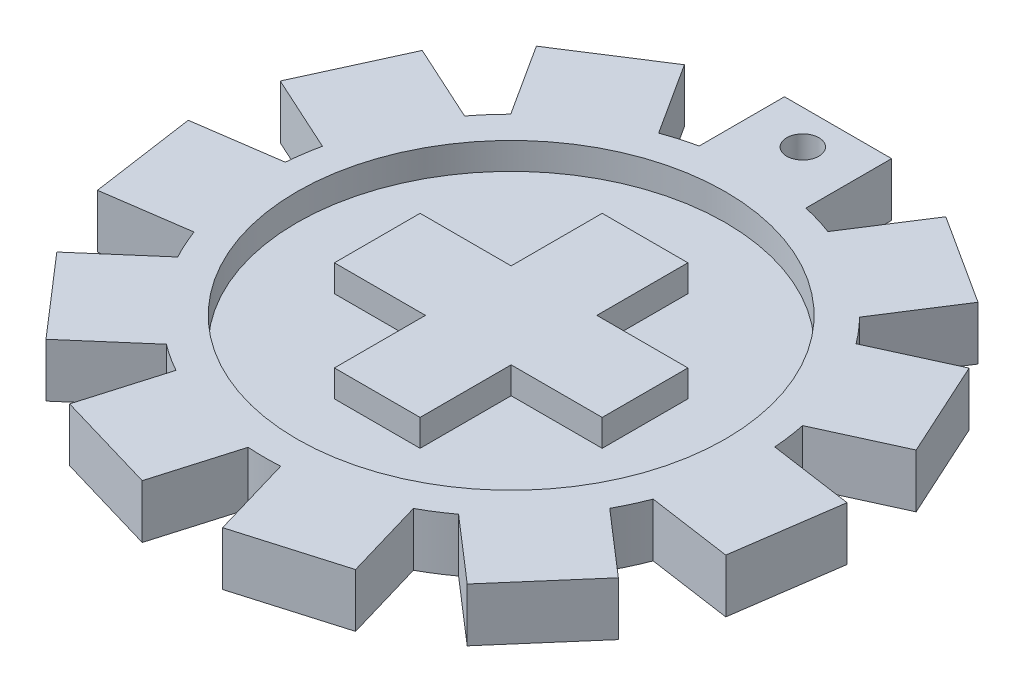
from build123d import *

# Parameters (mm, degrees)
SKETCH1_R           = 20
BOSS_EXTRUDE1_DEPTH = 2.5
SKETCH1_4_R         = 20
BOSS_EXTRUDE2_DEPTH = 5
SKETCH3_R           = 1.5
CUT_EXTRUDE1_DEPTH  = 7


with BuildPart() as part:
    # Sketch1 → Boss-Extrude1 (new body)
    with BuildSketch(Plane(origin=(0, 0, 0), x_dir=(1, 0, 0), z_dir=(0, 1, 0))):
        Circle(SKETCH1_R)
        Polygon((-12.5, -4), (-12.5, 4), (-4, 4), (-4, 12.5), (4, 12.5), (4, 4), (12.5, 4), (12.5, -4), (4, -4), (4, -12.5), (-4, -12.5), (-4, -4), align=None, mode=Mode.SUBTRACT)
    extrude(amount=BOSS_EXTRUDE1_DEPTH)

    # Sketch1_4 → Boss-Extrude2 (add)
    with BuildSketch(Plane(origin=(0, 0, 0), x_dir=(1, 0, 0), z_dir=(0, 1, 0))):
        with BuildLine():
            Line((-4.915686496, 30.430999893), (-4.915686496, 22.468556391))
            ThreePointArc((-4.915686496, 22.468556391), (-6.396922743, 22.09251863), (-7.849917421, 21.618945314))
            Line((-7.849917421, 21.618945314), (-12.175043961, 28.348973577))
            Line((-12.175043961, 28.348973577), (-20.587579289, 22.942565402))
            Line((-20.587579289, 22.942565402), (-16.282757325, 16.244131676))
            ThreePointArc((-16.282757325, 16.244131676), (-17.325551189, 15.126971805), (-18.29185503, 13.94302835))
            Line((-18.29185503, 13.94302835), (-25.568910993, 17.266348454))
            Line((-25.568910993, 17.266348454), (-29.723061123, 8.170028501))
            Line((-29.723061123, 8.170028501), (-22.480167752, 4.86230993))
            ThreePointArc((-22.480167752, 4.86230993), (-22.753439548, 3.358718315), (-22.926257911, 1.840298402))
            Line((-22.926257911, 1.840298402), (-30.844829446, 0.701779696))
            Line((-30.844829446, 0.701779696), (-29.421681063, -9.196434723))
            Line((-29.421681063, -9.196434723), (-21.540283755, -8.063260864))
            ThreePointArc((-21.540283755, -8.063260864), (-20.957271619, -9.475904509), (-20.281735894, -10.846713286))
            Line((-20.281735894, -10.846713286), (-26.327732489, -16.085599158))
            Line((-26.327732489, -16.085599158), (-19.77912515, -23.643094901))
            Line((-19.77912515, -23.643094901), (-13.761511862, -18.428803305))
            ThreePointArc((-13.761511862, -18.428803305), (-12.507318028, -19.301994605), (-11.197906035, -20.089970145))
            Line((-11.197906035, -20.089970145), (-13.45176649, -27.765913934))
            Line((-13.45176649, -27.765913934), (-3.856836754, -30.583239502))
            Line((-3.856836754, -30.583239502), (-1.613557187, -22.943330909))
            ThreePointArc((-1.613557187, -22.943330909), (-0.086379336, -22.999837795), (1.441179869, -22.954803432))
            Line((1.441179869, -22.954803432), (3.695040324, -30.630747221))
            Line((3.695040324, -30.630747221), (13.28997006, -27.813421652))
            Line((13.28997006, -27.813421652), (11.046690494, -20.173513059))
            ThreePointArc((11.046690494, -20.173513059), (12.361984186, -19.395394995), (13.622701348, -18.53164882))
            Line((13.622701348, -18.53164882), (19.668697943, -23.770534691))
            Line((19.668697943, -23.770534691), (26.217305283, -16.213038948))
            Line((26.217305283, -16.213038948), (20.199691995, -10.998747352))
            ThreePointArc((20.199691995, -10.998747352), (20.885505074, -9.633051324), (21.479111403, -8.224826646))
            Line((21.479111403, -8.224826646), (29.397682938, -9.363345352))
            Line((29.397682938, -9.363345352), (30.82083132, 0.534869067))
            Line((30.82083132, 0.534869067), (22.939434012, 1.668042926))
            ThreePointArc((22.939434012, 1.668042926), (22.778025671, 3.187718078), (22.516055351, 4.693319874))
            Line((22.516055351, 4.693319874), (29.793111314, 8.016639978))
            Line((29.793111314, 8.016639978), (25.638961184, 17.112959932))
            Line((25.638961184, 17.112959932), (18.396067813, 13.805241361))
            ThreePointArc((18.396067813, 13.805241361), (17.438684059, 14.996409513), (16.404310816, 16.121370496))
            Line((16.404310816, 16.121370496), (20.729437356, 22.851398758))
            Line((20.729437356, 22.851398758), (12.316902027, 28.257806933))
            Line((12.316902027, 28.257806933), (8.012080063, 21.559373207))
            ThreePointArc((8.012080063, 21.559373207), (6.562683475, 22.043846888), (5.084313504, 22.430999893))
            Line((5.084313504, 22.430999893), (5.084313504, 30.430999893))
            Line((5.084313504, 30.430999893), (-4.915686496, 30.430999893))
        make_face()
        Circle(SKETCH1_4_R, mode=Mode.SUBTRACT)
        Polygon((-4, 4), (-12.5, 4), (-12.5, -4), (-4, -4), (-4, -12.5), (4, -12.5), (4, -4), (12.5, -4), (12.5, 4), (4, 4), (4, 12.5), (-4, 12.5), align=None)
    extrude(amount=BOSS_EXTRUDE2_DEPTH)

    # Sketch3 → Cut-Extrude1 (cut)
    with BuildSketch(Plane(origin=(0, 5, 0), x_dir=(1, 0, 0), z_dir=(0, 1, 0))):
        with Locations((0, 27.225870762)):
            Circle(SKETCH3_R)
    extrude(amount=-CUT_EXTRUDE1_DEPTH, mode=Mode.SUBTRACT)


solid = part.part
